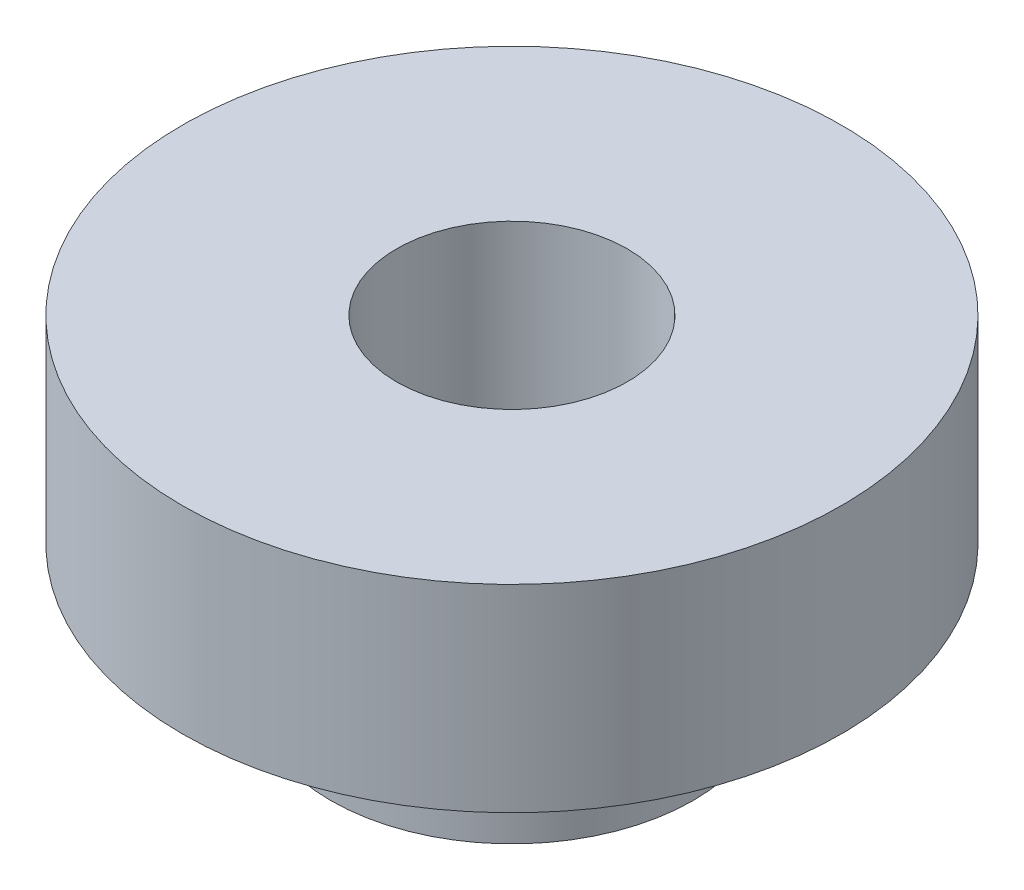
from build123d import *

# Parameters (mm, degrees)
SKETCH1_R           = 57.15
SKETCH1_R_2         = 1.397
SKETCH1_R_3         = 3.175
BOSS_EXTRUDE1_DEPTH = 4.572
SKETCH2_R           = 2.75
SKETCH2_R_2         = 1.75
BOSS_EXTRUDE2_DEPTH = 2
SKETCH3_R           = 5
SKETCH3_R_2         = 1.75
BOSS_EXTRUDE3_DEPTH = 3


with BuildPart() as part:
    # Sketch1 → Boss-Extrude1 (new body)
    with BuildSketch(Plane(origin=(0, 0, 0), x_dir=(1, 0, 0), z_dir=(0, 1, 0))):
        Circle(SKETCH1_R)
        with Locations((0, 6.35)):
            Circle(SKETCH1_R_2, mode=Mode.SUBTRACT)
        with Locations((0, 25.4)):
            Circle(SKETCH1_R_3, mode=Mode.SUBTRACT)
        with Locations((0, 50.8)):
            Circle(SKETCH1_R_3, mode=Mode.SUBTRACT)
        with Locations((25.4, 0)):
            Circle(SKETCH1_R_3, mode=Mode.SUBTRACT)
        with Locations((0, -25.4)):
            Circle(SKETCH1_R_3, mode=Mode.SUBTRACT)
        with Locations((-25.4, 0)):
            Circle(SKETCH1_R_3, mode=Mode.SUBTRACT)
        with Locations((6.35, 0)):
            Circle(SKETCH1_R_2, mode=Mode.SUBTRACT)
        with Locations((0, -6.35)):
            Circle(SKETCH1_R_2, mode=Mode.SUBTRACT)
        with Locations((-6.35, 0)):
            Circle(SKETCH1_R_2, mode=Mode.SUBTRACT)
        with Locations((35.921024484, 35.921024484)):
            Circle(SKETCH1_R_3, mode=Mode.SUBTRACT)
        with Locations((50.8, 0)):
            Circle(SKETCH1_R_3, mode=Mode.SUBTRACT)
        with Locations((35.921024484, -35.921024484)):
            Circle(SKETCH1_R_3, mode=Mode.SUBTRACT)
        with Locations((0, -50.8)):
            Circle(SKETCH1_R_3, mode=Mode.SUBTRACT)
        with Locations((-35.921024484, -35.921024484)):
            Circle(SKETCH1_R_3, mode=Mode.SUBTRACT)
        with Locations((-50.8, 0)):
            Circle(SKETCH1_R_3, mode=Mode.SUBTRACT)
        with Locations((-35.921024484, 35.921024484)):
            Circle(SKETCH1_R_3, mode=Mode.SUBTRACT)
    extrude(amount=BOSS_EXTRUDE1_DEPTH)


with BuildPart() as body_2:
    # Sketch2 → Boss-Extrude2 (new body)
    with BuildSketch(Plane(origin=(0, 4.572, 0), x_dir=(1, 0, 0), z_dir=(0, 1, 0))):
        with Locations((-25.4, 0)):
            Circle(SKETCH2_R)
        with Locations((-25.4, 0)):
            Circle(SKETCH2_R_2, mode=Mode.SUBTRACT)
    extrude(amount=-BOSS_EXTRUDE2_DEPTH)

    # Sketch3 → Boss-Extrude3 (add)
    with BuildSketch(Plane(origin=(0, 4.572, 0), x_dir=(1, 0, 0), z_dir=(0, 1, 0))):
        with Locations((-25.4, 0)):
            Circle(SKETCH3_R)
        with Locations((-25.4, 0)):
            Circle(SKETCH3_R_2, mode=Mode.SUBTRACT)
    extrude(amount=BOSS_EXTRUDE3_DEPTH)


solid = body_2.part
